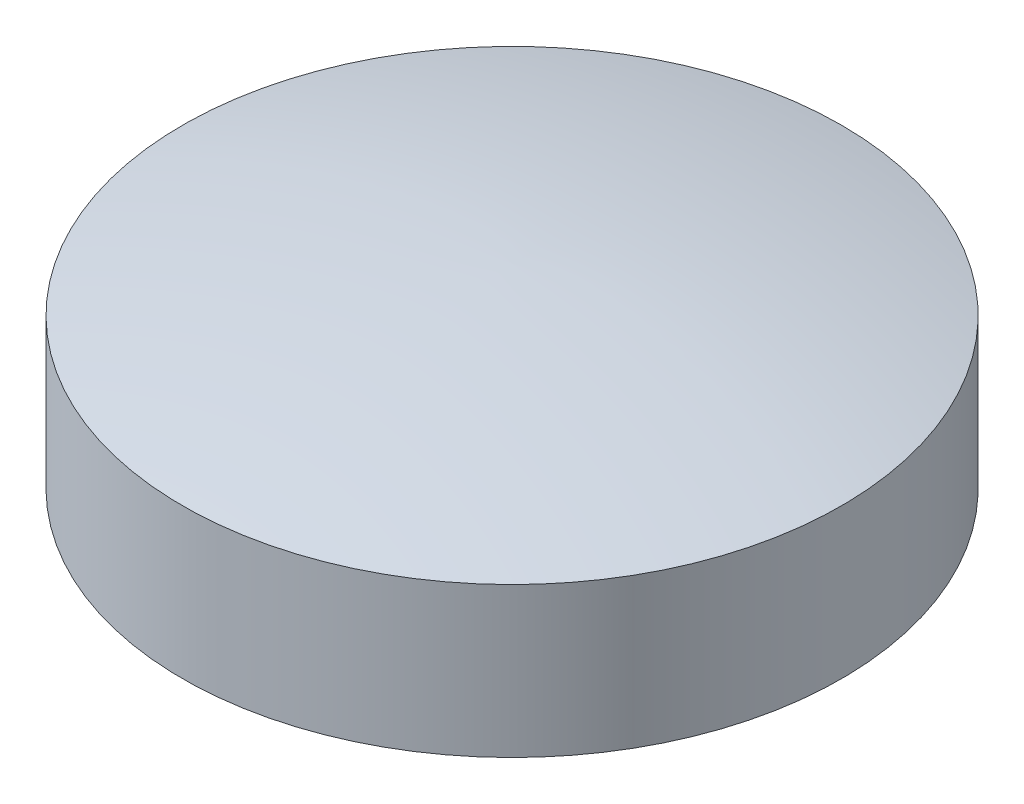
from build123d import *


with BuildPart() as part:
    # Sketch2 → Revolve1 (revolve)
    with BuildSketch(Plane.XY, mode=Mode.PRIVATE) as revolve1_sk:
        with BuildLine():
            Line((0, 0), (22, 0))
            Line((22, 0), (22, 10))
            ThreePointArc((22, 10), (11.08966446, 12.157539375), (0, 13))
            Line((0, 13), (0, 0))
        make_face()
    revolve(revolve1_sk.sketch.rotate(Axis((0, 0, 0), (0, 1, 0)), 90), axis=Axis((0, 0, 0), (0, 1, 0)))  # turned: the seam where the file's is


solid = part.part
